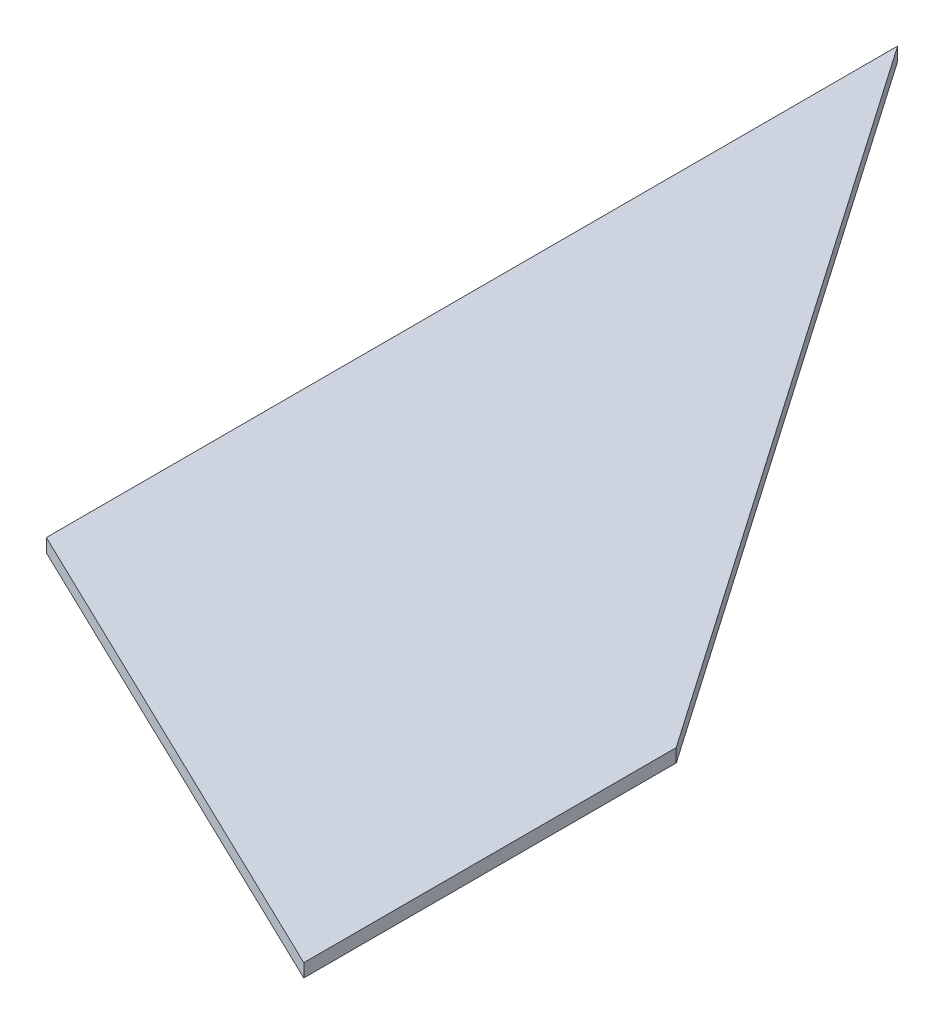
from build123d import *

# Parameters (mm, degrees)
BOSS_EXTRUDE1_DEPTH = 3.175


with BuildPart() as part:
    # Sketch1 → Boss-Extrude1 (new body)
    with BuildSketch(Plane(origin=(0, 0, 0), x_dir=(1, 0, 0), z_dir=(0, 1, 0))):
        Polygon((0, 0), (0, 203.2), (118.599189008, 31.75), (118.599189008, -57.15), align=None)
    extrude(amount=BOSS_EXTRUDE1_DEPTH)


solid = part.part
